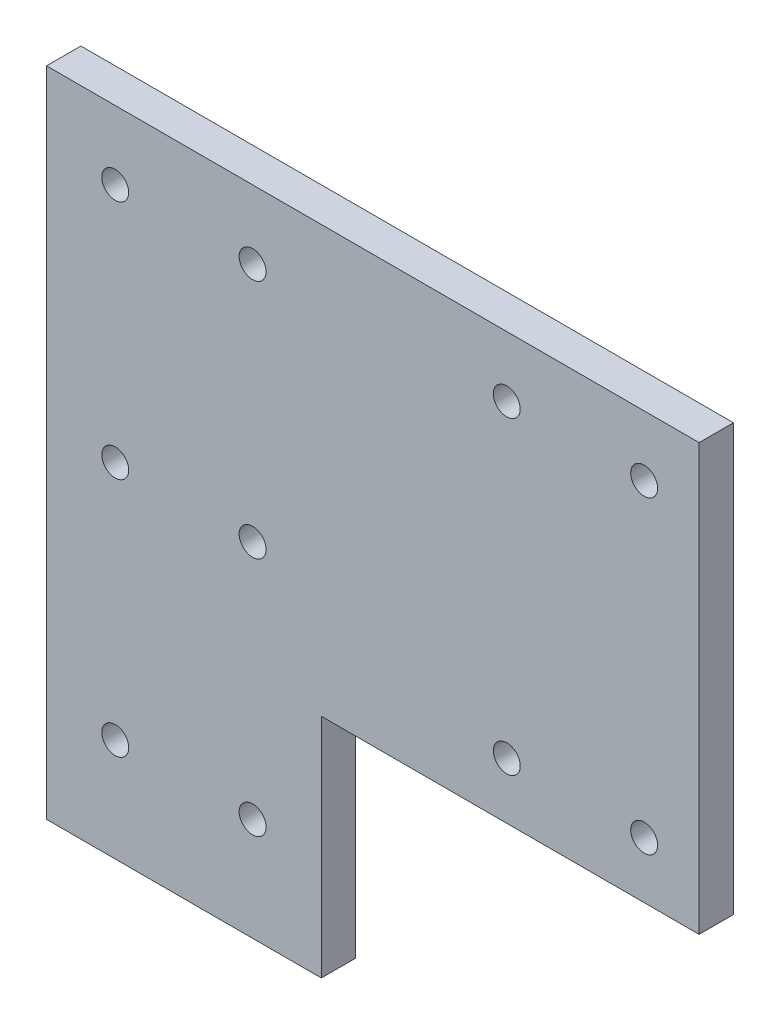
from build123d import *

# Parameters (mm, degrees)
BOSS_EXTRUDE1_DEPTH = 6.35
SKETCH2_R           = 2.4892
CUT_EXTRUDE1_DEPTH  = 7.35


with BuildPart() as part:
    # Sketch1 → Boss-Extrude1 (new body)
    with BuildSketch(Plane.XY):
        Polygon((0, 0), (0, 120.65), (120.65, 120.65), (120.65, 41.91), (50.8, 41.91), (50.8, 0), align=None)
    extrude(amount=BOSS_EXTRUDE1_DEPTH)

    # Sketch2 → Cut-Extrude1 (cut, through all)
    with BuildSketch(Plane(origin=(0, 0, 0), x_dir=(-1, 0, 0), z_dir=(0, 0, -1))):
        with Locations((-110.49, 109.474)):
            Circle(SKETCH2_R)
        with Locations((-85.09, 109.474)):
            Circle(SKETCH2_R)
        with Locations((-85.09, 52.324)):
            Circle(SKETCH2_R)
        with Locations((-110.49, 52.324)):
            Circle(SKETCH2_R)
        with Locations((-38.1, 107.95)):
            Circle(SKETCH2_R)
        with Locations((-12.7, 107.95)):
            Circle(SKETCH2_R)
        with Locations((-12.7, 19.05)):
            Circle(SKETCH2_R)
        with Locations((-38.1, 19.05)):
            Circle(SKETCH2_R)
        with Locations((-38.1, 63.5)):
            Circle(SKETCH2_R)
        with Locations((-12.7, 63.5)):
            Circle(SKETCH2_R)
    extrude(amount=-CUT_EXTRUDE1_DEPTH, mode=Mode.SUBTRACT)


solid = part.part
